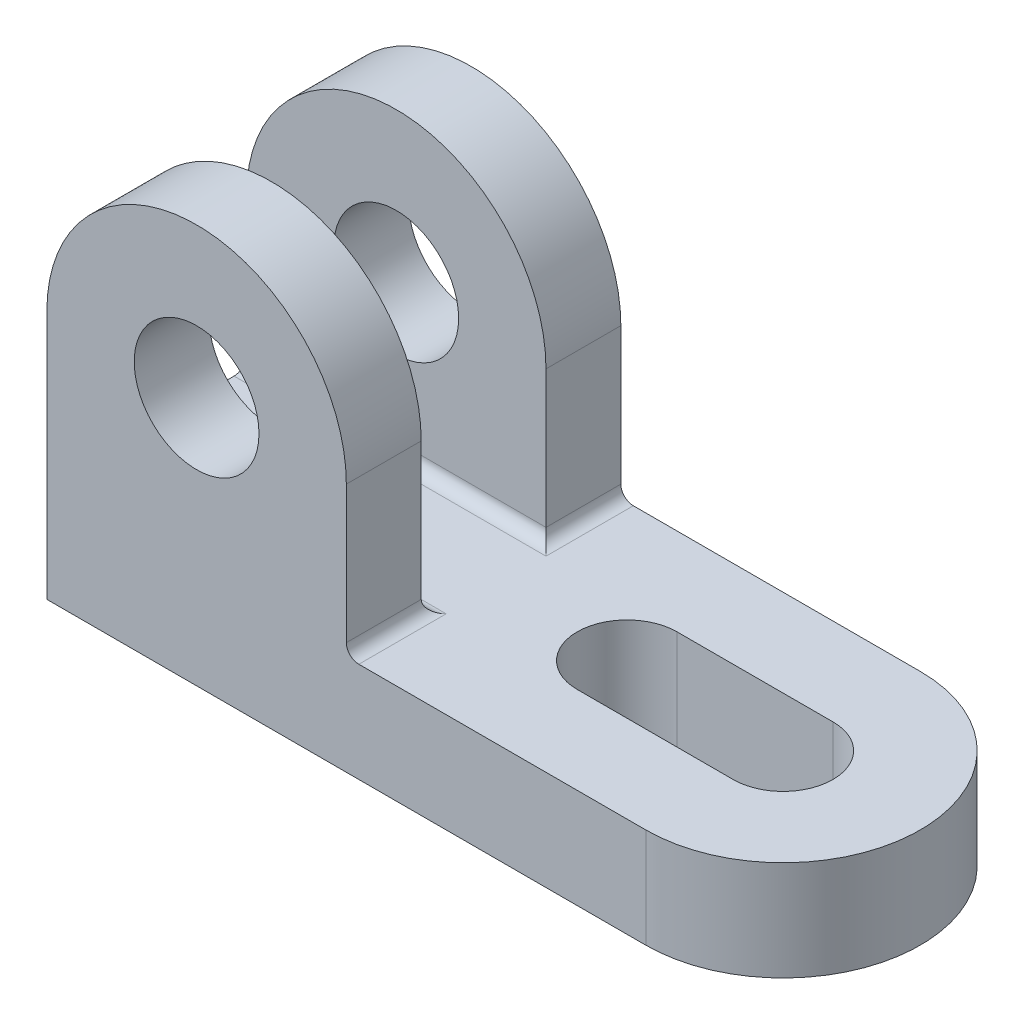
from build123d import *

# Parameters (mm, degrees)
SKETCH2_R           = 22
BOSS_EXTRUDE1_DEPTH = 16
CUT_EXTRUDE1_DEPTH  = 17
BOSS_EXTRUDE2_DEPTH = 12
FILLET1_R           = 2


with BuildPart() as part:
    # Sketch2 → Boss-Extrude1 (new body)
    with BuildSketch(Plane(origin=(0, 0, 0), x_dir=(1, 0, 0), z_dir=(0, 1, 0))):
        with BuildLine():
            Line((37.000000064, 22), (-59, 22))
            Line((-59, 22), (-59, -22))
            Line((-59, -22), (37, -22))
            ThreePointArc((37, -22), (15, 3.2e-08), (37.000000064, 22))
        make_face()
        with Locations((37, 0)):
            Circle(SKETCH2_R)
    extrude(amount=BOSS_EXTRUDE1_DEPTH)

    # Sketch5 → Cut-Extrude1 (cut, through all)
    with BuildSketch(Plane(origin=(0, 16, 0), x_dir=(1, 0, 0), z_dir=(0, 1, 0))):
        with BuildLine():
            Line((37, -8), (12, -8))
            ThreePointArc((12, -8), (4, 0), (12, 8))
            Line((12, 8), (37, 8))
            ThreePointArc((37, 8), (45, 0), (37, -8))
        make_face()
    extrude(amount=-CUT_EXTRUDE1_DEPTH, mode=Mode.SUBTRACT)

    # Sketch6 → Boss-Extrude2 (add)
    with BuildSketch(Plane.XY.offset(22)):
        with BuildLine():
            ThreePointArc((-59, 40), (-51.970562748, 23.029437252), (-35, 16))
            ThreePointArc((-35, 16), (-18.029437252, 23.029437252), (-11, 40))
            Line((-11, 40), (-25, 40))
            ThreePointArc((-25, 40), (-35, 30), (-45, 40))
            Line((-45, 40), (-59, 40))
        make_face()
        with BuildLine():
            ThreePointArc((-11, 40), (-35, 64), (-59, 40))
            Line((-59, 40), (-45, 40))
            ThreePointArc((-45, 40), (-35, 50), (-25, 40))
            Line((-25, 40), (-11, 40))
        make_face()
        with BuildLine():
            ThreePointArc((-11, 40), (-18.029437252, 23.029437252), (-35, 16))
            Line((-35, 16), (-11, 16))
            Line((-11, 16), (-11, 40))
        make_face()
        with BuildLine():
            Line((-59, 40), (-59, 16))
            Line((-59, 16), (-35, 16))
            ThreePointArc((-35, 16), (-51.970562748, 23.029437252), (-59, 40))
        make_face()
    boss_extrude2 = extrude(amount=-BOSS_EXTRUDE2_DEPTH)

    # Mirror1: Boss-Extrude2 across plane
    add(boss_extrude2.mirror(Plane.XY))

    # Fillet1
    fillet1_edges = [part.edges().sort_by_distance(p)[0] for p in [
        (-11, 16, 16),
        (-35, 16, 10),
        (-35, 16, -10),
        (-11, 16, -16),
    ]]
    fillet(fillet1_edges, radius=FILLET1_R)


solid = part.part
